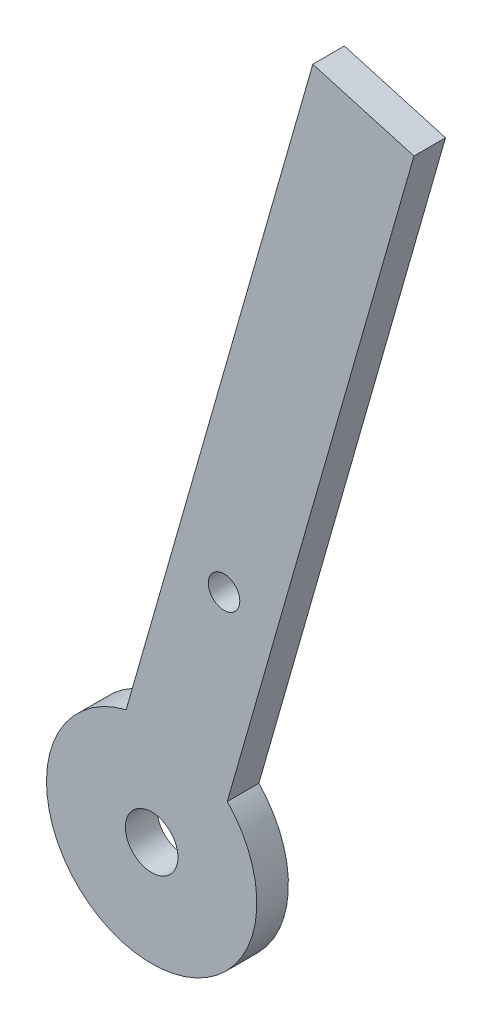
from build123d import *

# Parameters (mm, degrees)
SKETCH1_R           = 2.5
SKETCH1_R_2         = 1.500000002
BOSS_EXTRUDE1_DEPTH = 3


with BuildPart() as part:
    # Sketch1 → Boss-Extrude1 (new body)
    with BuildSketch(Plane.XY):
        with BuildLine():
            Line((-87.0843481, -3.036998705), (-104.827895583, -65.04932222))
            ThreePointArc((-104.827895583, -65.04932222), (-114.768238381, -81.614184605), (-114.442080188, -62.298421571))
            Line((-114.442080188, -62.298421571), (-96.698532704, -0.286098055))
            Line((-96.698532704, -0.286098055), (-87.0843481, -3.036998705))
        make_face()
        with Locations((-112.017337731, -72)):
            Circle(SKETCH1_R, mode=Mode.SUBTRACT)
        with Locations((-105.140086107, -47.964538488)):
            Circle(SKETCH1_R_2, mode=Mode.SUBTRACT)
    extrude(amount=BOSS_EXTRUDE1_DEPTH)


solid = part.part
